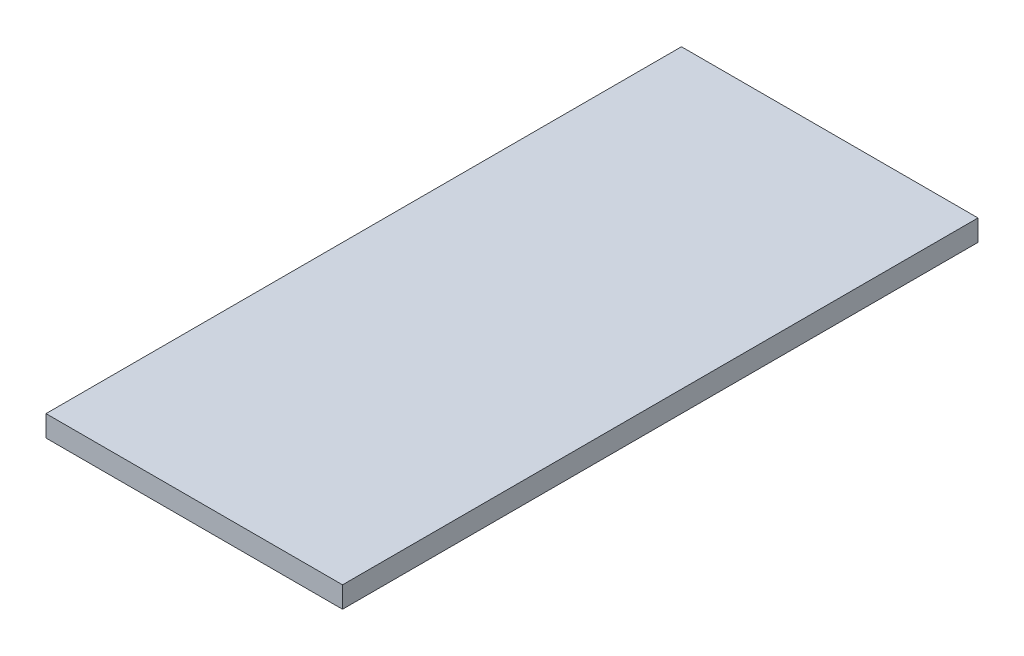
from build123d import *

# Parameters (mm, degrees)
SKETCH1_W           = 70
SKETCH1_H           = 150
BOSS_EXTRUDE1_DEPTH = 5


with BuildPart() as part:
    # Sketch1 → Boss-Extrude1 (new body)
    with BuildSketch(Plane(origin=(0, 0, 0), x_dir=(1, 0, 0), z_dir=(0, 1, 0))):
        with Locations((-8.016759777, -40)):
            Rectangle(SKETCH1_W, SKETCH1_H)
    extrude(amount=BOSS_EXTRUDE1_DEPTH)


solid = part.part
